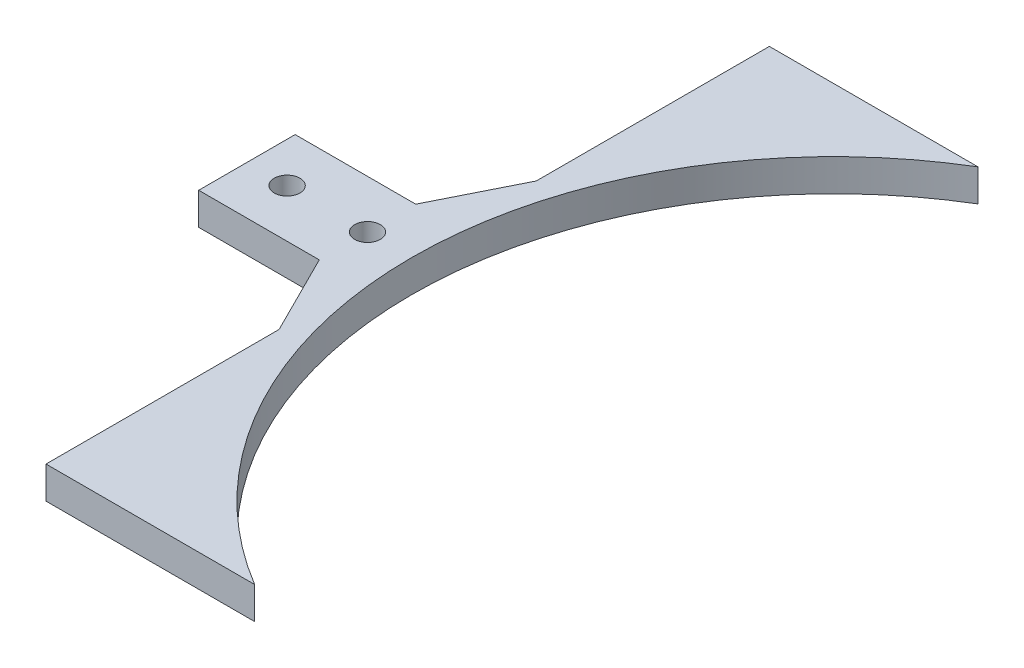
from build123d import *

# Parameters (mm, degrees)
SKETCH_2_R      = 1.6
EXTRUDE_1_DEPTH = 4


with BuildPart() as part:
    # 草图2 → 凸台-拉伸1 (new body)
    with BuildSketch(Plane(origin=(0, 0, 0), x_dir=(1, 0, 0), z_dir=(0, 1, 0))):
        with BuildLine():
            Line((-21.264895519, 46.809256481), (4.693469915, 46.809256481))
            ThreePointArc((4.693469915, 46.809256481), (-20.764895519, 1.809256481), (4.693469915, -43.190743519))
            Line((4.693469915, -43.190743519), (-21.264895519, -43.190743519))
            Line((-21.264895519, -43.190743519), (-21.264895519, -14.190743519))
            Line((-21.264895519, -14.190743519), (-26.264895519, -4.190743519))
            Line((-26.264895519, -4.190743519), (-41.264895519, -4.190743519))
            Line((-41.264895519, -4.190743519), (-41.264895519, 7.809256481))
            Line((-41.264895519, 7.809256481), (-26.264895519, 7.809256481))
            Line((-26.264895519, 7.809256481), (-21.264895519, 17.809256481))
            Line((-21.264895519, 17.809256481), (-21.264895519, 46.809256481))
        make_face()
        with Locations((-36.264895519, 1.809256481)):
            Circle(SKETCH_2_R, mode=Mode.SUBTRACT)
        with Locations((-26.264895519, 1.809256481)):
            Circle(SKETCH_2_R, mode=Mode.SUBTRACT)
    extrude(amount=EXTRUDE_1_DEPTH)


solid = part.part
